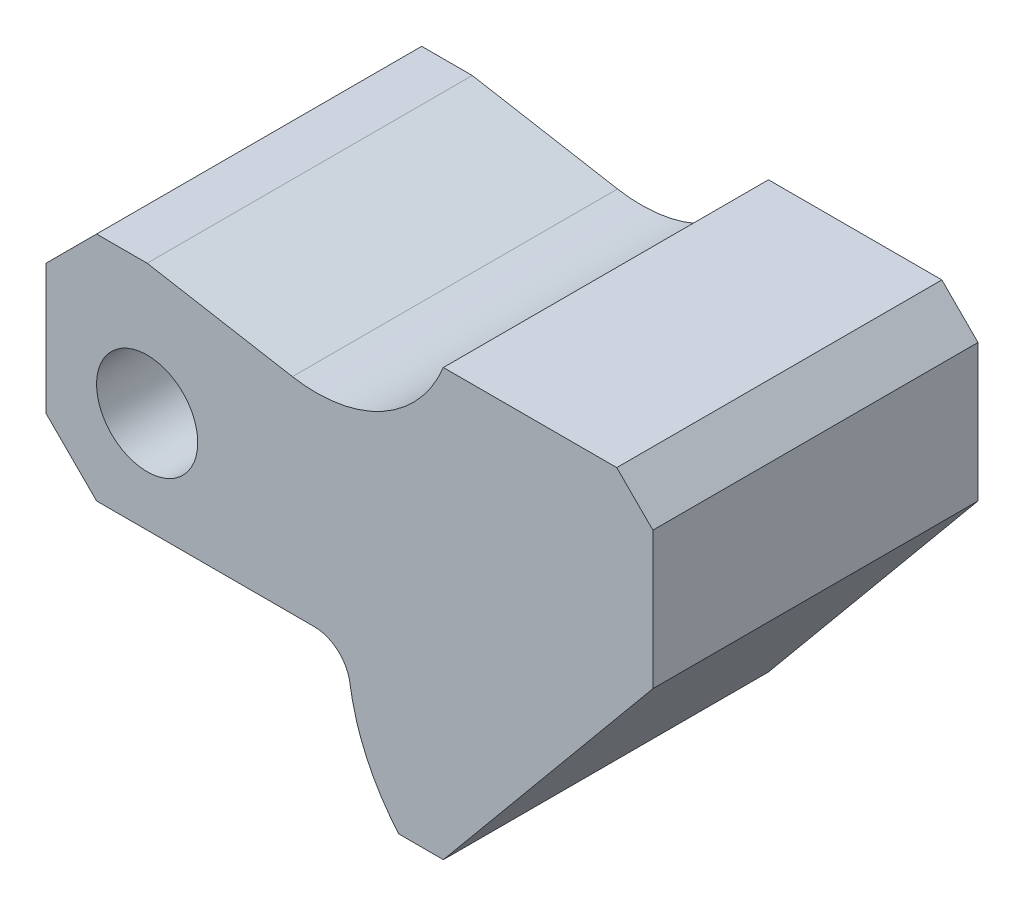
from build123d import *

# Parameters (mm, degrees)
SKETCH1_R           = 7
BOSS_EXTRUDE1_DEPTH = 45


with BuildPart() as part:
    # Sketch1 → Boss-Extrude1 (new body)
    with BuildSketch(Plane.XY):
        with BuildLine():
            Line((-7, -14), (23.112513701, -14))
            ThreePointArc((23.112513701, -14), (26.377749482, -15.213413768), (28.058152443, -18.264705882))
            ThreePointArc((28.058152443, -18.264705882), (30.394982646, -26.115672061), (34.833954843, -33))
            Line((34.833954843, -33), (41, -33))
            Line((41, -33), (70, 2))
            Line((70, 2), (70, 21))
            Line((70, 21), (65, 26))
            Line((65, 26), (41, 26))
            ThreePointArc((41, 26), (32.591637328, 16.535902458), (20.104042352, 14.455114912))
            Line((20.104042352, 14.455114912), (0, 18))
            Line((0, 18), (-7, 18))
            Line((-7, 18), (-14, 11))
            Line((-14, 11), (-14, -7))
            Line((-14, -7), (-7, -14))
        make_face()
        Circle(SKETCH1_R, mode=Mode.SUBTRACT)
    extrude(amount=BOSS_EXTRUDE1_DEPTH)


solid = part.part
